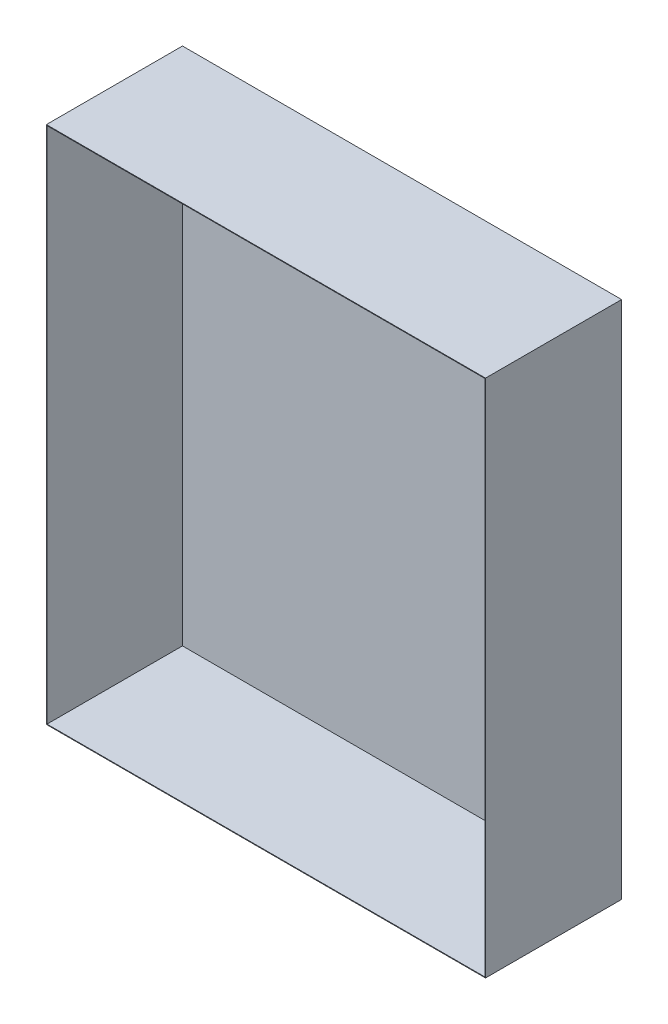
from build123d import *

# Parameters (mm, degrees)
SKETCH1_W           = 1803.4
SKETCH1_H           = 558.8
BOSS_EXTRUDE1_DEPTH = 2133.6
SHELL1_T            = -2.54


with BuildPart() as part:
    # Sketch1 → Boss-Extrude1 (new body)
    with BuildSketch(Plane(origin=(0, 0, 0), x_dir=(1, 0, 0), z_dir=(0, 1, 0))):
        Rectangle(SKETCH1_W, SKETCH1_H)
    extrude(amount=BOSS_EXTRUDE1_DEPTH)

    # Shell1
    shell1_openings = [part.faces().sort_by_distance(p)[0] for p in [
        (0, 1066.8, 279.4),
    ]]
    offset(amount=SHELL1_T, openings=shell1_openings, kind=Kind.INTERSECTION)


solid = part.part
